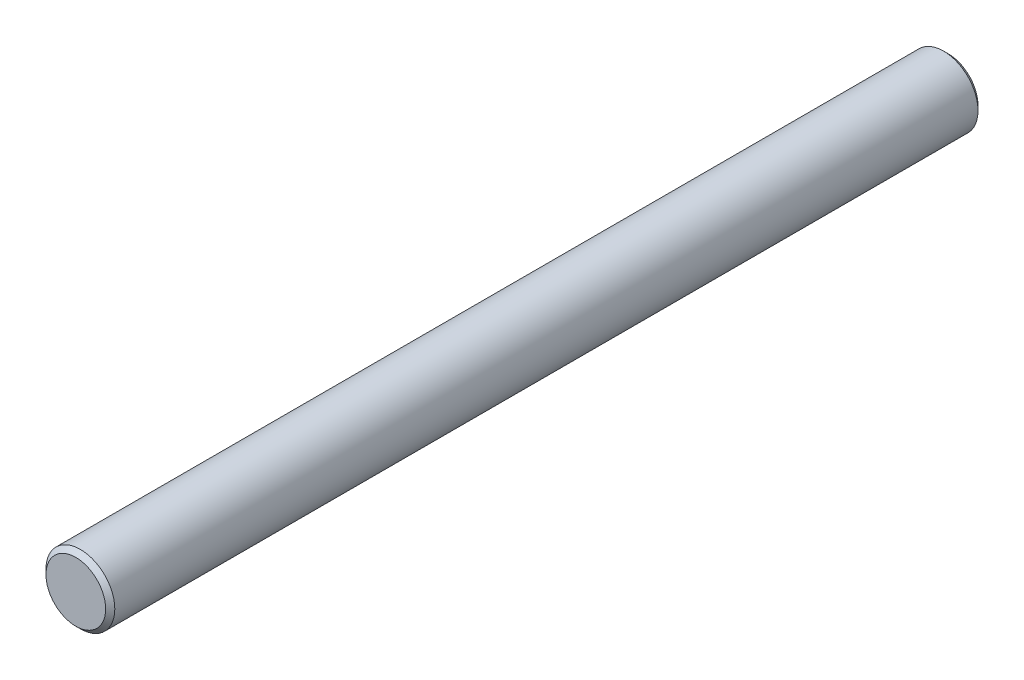
from build123d import *

# Parameters (mm, degrees)
SKETCH1_R           = 0.75
BOSS_EXTRUDE1_DEPTH = 19
CHAMFER1_SIZE       = 0.1


with BuildPart() as part:
    # Sketch1 → Boss-Extrude1 (new body)
    with BuildSketch(Plane.XY):
        Circle(SKETCH1_R)
    extrude(amount=BOSS_EXTRUDE1_DEPTH)

    # Chamfer1
    chamfer1_edges = [part.edges().sort_by_distance(p)[0] for p in [
        (-0.75, 0, 0),
        (-0.75, 0, 19),
    ]]
    chamfer(chamfer1_edges, length=CHAMFER1_SIZE)


solid = part.part
